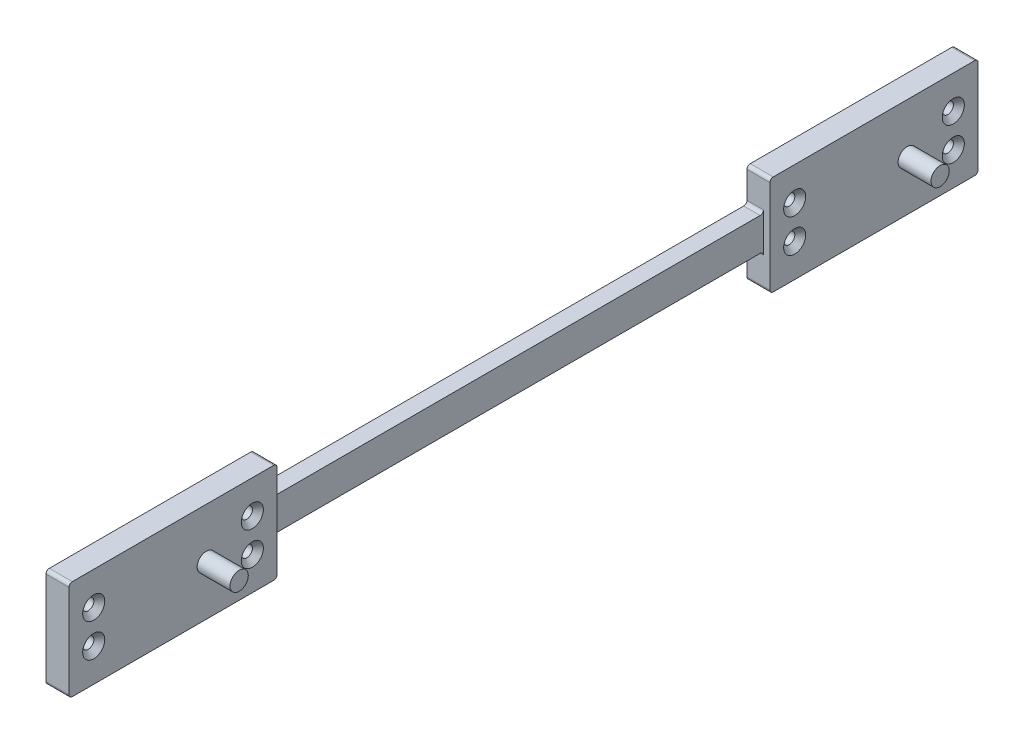
from build123d import *

# Parameters (mm, degrees)
BOSS_EXTRUDE1_DEPTH           = 5
CUT_EXTRUDE3_DEPTH            = 246.469607284
CUT_EXTRUDE5_DEPTH            = 246.469607284
SKETCH7_W                     = 63.3
SKETCH7_H                     = 30.32
BOSS_EXTRUDE2_DEPTH           = 2
SKETCH10_R                    = 2.78
BOSS_EXTRUDE3_DEPTH           = 10
SKETCH11_W                    = 63.3
SKETCH11_H                    = 30.32
BOSS_EXTRUDE4_DEPTH           = 2
SKETCH12_R                    = 2.78
BOSS_EXTRUDE5_DEPTH           = 10
FILLET1_R                     = 1
CSK_FOR_M3_SFHCS1_D           = 3.4
CSK_FOR_M3_SFHCS1_CSINK_D     = 6.72
CSK_FOR_M3_SFHCS1_CSINK_ANGLE = 90


with BuildPart() as part:
    # Sketch2 → Boss-Extrude1 (new body)
    with BuildSketch(Plane(origin=(0, 0, 0), x_dir=(0, 0, -1), z_dir=(1, 0, 0))):
        Polygon((31.65, -15.16), (31.65, -5), (181.65, -5), (181.65, -15.16), (244.95, -15.16), (244.95, 15.16), (181.65, 15.16), (181.65, 5), (31.65, 5), (31.65, 15.16), (-31.65, 15.16), (-31.65, -15.16), align=None)
    extrude(amount=BOSS_EXTRUDE1_DEPTH)

    # Sketch1 → Cut-Extrude3 (cut, through all)
    with BuildSketch(Plane(origin=(0, 0, 0), x_dir=(0, 0, -1), z_dir=(1, 0, 0))):
        Polygon((20.32, 10.16), (-20.32, 10.16), (-20.32, -10.16), (20.32, -10.16), (20.32, -3.19), (22.7, -3.19), (22.7, 3.16), (20.32, 3.16), align=None)
    extrude(amount=CUT_EXTRUDE3_DEPTH, mode=Mode.SUBTRACT)

    # Sketch3 → Cut-Extrude5 (cut, through all)
    with BuildSketch(Plane(origin=(5, 0, 0), x_dir=(0, 0, -1), z_dir=(1, 0, 0))):
        Polygon((192.98, 10.16), (192.98, -10.16), (233.62, -10.16), (233.62, -3.175), (236, -3.175), (236, 3.175), (233.62, 3.175), (233.62, 10.16), align=None)
    extrude(amount=-CUT_EXTRUDE5_DEPTH, mode=Mode.SUBTRACT)

    # Sketch7 → Boss-Extrude2 (add)
    with BuildSketch(Plane(origin=(5, 0, 0), x_dir=(0, 0, -1), z_dir=(1, 0, 0))):
        Rectangle(SKETCH7_W, SKETCH7_H)
    extrude(amount=BOSS_EXTRUDE2_DEPTH)

    # Sketch10 → Boss-Extrude3 (add)
    with BuildSketch(Plane(origin=(7, 0, 0), x_dir=(0, 0, -1), z_dir=(1, 0, 0))):
        with Locations((10.12, 0)):
            Circle(SKETCH10_R)
    extrude(amount=BOSS_EXTRUDE3_DEPTH)

    # Sketch11 → Boss-Extrude4 (add)
    with BuildSketch(Plane(origin=(5, 0, 0), x_dir=(0, 0, -1), z_dir=(1, 0, 0))):
        with Locations((213.3, 0)):
            Rectangle(SKETCH11_W, SKETCH11_H)
    extrude(amount=BOSS_EXTRUDE4_DEPTH)

    # Sketch12 → Boss-Extrude5 (add)
    with BuildSketch(Plane(origin=(7, 0, 0), x_dir=(0, 0, -1), z_dir=(1, 0, 0))):
        with Locations((223.42, 0)):
            Circle(SKETCH12_R)
    extrude(amount=BOSS_EXTRUDE5_DEPTH)

    # Fillet1
    fillet1_edges = [part.edges().sort_by_distance(p)[0] for p in [
        (3.5, -15.16, -244.95),
        (3.5, 15.16, -244.95),
        (3.5, 15.16, -181.65),
        (2.5, 5, -181.65),
        (3.5, -15.16, -181.65),
        (2.5, -5, -181.65),
        (2.5, -5, -31.65),
        (2.5, 5, -31.65),
        (3.5, 15.16, -31.65),
        (3.5, -15.16, -31.65),
        (3.5, -15.16, 31.65),
        (3.5, 15.16, 31.65),
    ]]
    fillet(fillet1_edges, radius=FILLET1_R)

    # CSK for M3 SFHCS1 (through all)
    with Locations(Plane(origin=(7, 0, 0), x_dir=(0, 0, -1), z_dir=(1, 0, 0))):
        with Locations((-24.13, 5.08), (-24.13, -5.08), (24.13, -5.08), (24.13, 5.08), (189.17, 5.08), (189.17, -5.08), (237.43, 5.08), (237.43, -5.08)):
            CounterSinkHole(CSK_FOR_M3_SFHCS1_D / 2, CSK_FOR_M3_SFHCS1_CSINK_D / 2, counter_sink_angle=CSK_FOR_M3_SFHCS1_CSINK_ANGLE)


solid = part.part
